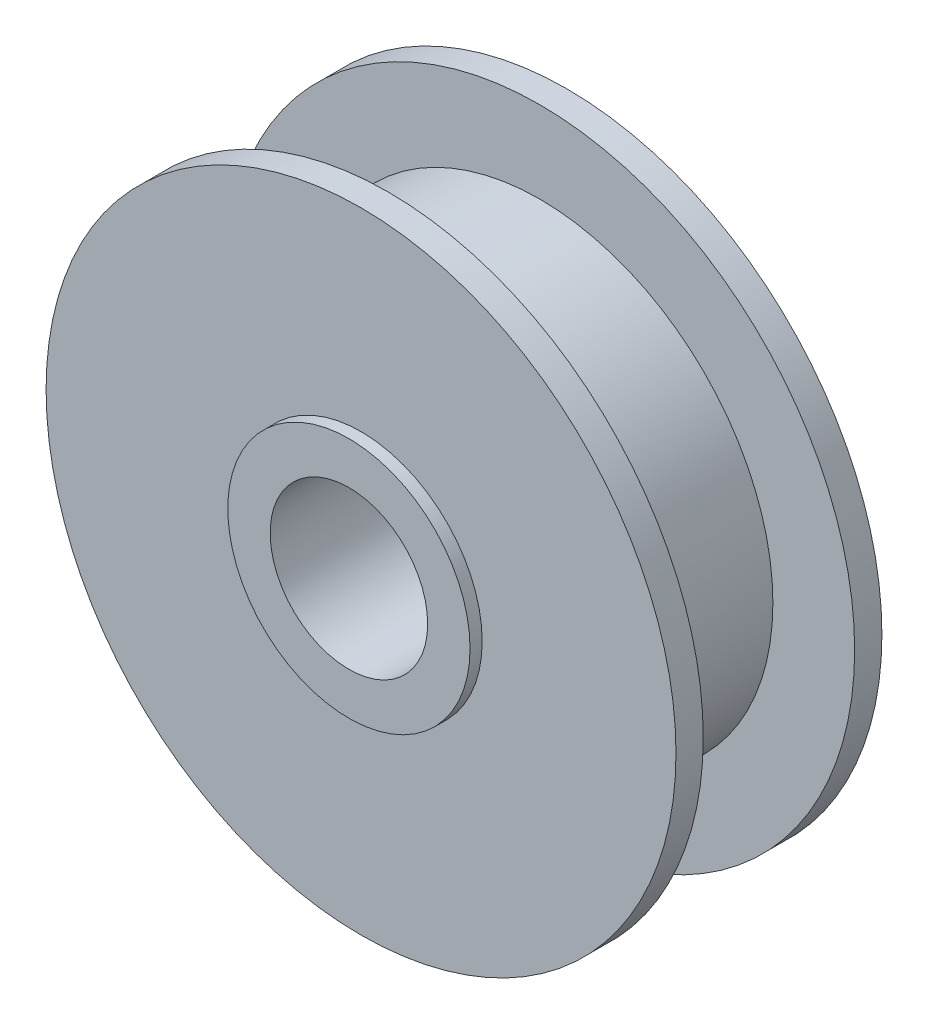
from build123d import *


with BuildPart() as part:
    # Sketch1 → Revolve1 (revolve)
    with BuildSketch(Plane(origin=(0, 0, 0), x_dir=(0, 0, -1), z_dir=(1, 0, 0))):
        Polygon((-1.9, 1.3), (-1.9, 2), (-1.7, 2), (-1.7, 5.2), (-1.25, 5.2), (-1.25, 3.85), (1.25, 3.85), (1.25, 5.2), (1.7, 5.2), (1.7, 2), (1.9, 2), (1.9, 1.3), align=None)
    revolve(axis=Axis((0, 0, 1.9), (0, 0, -1)))


solid = part.part
